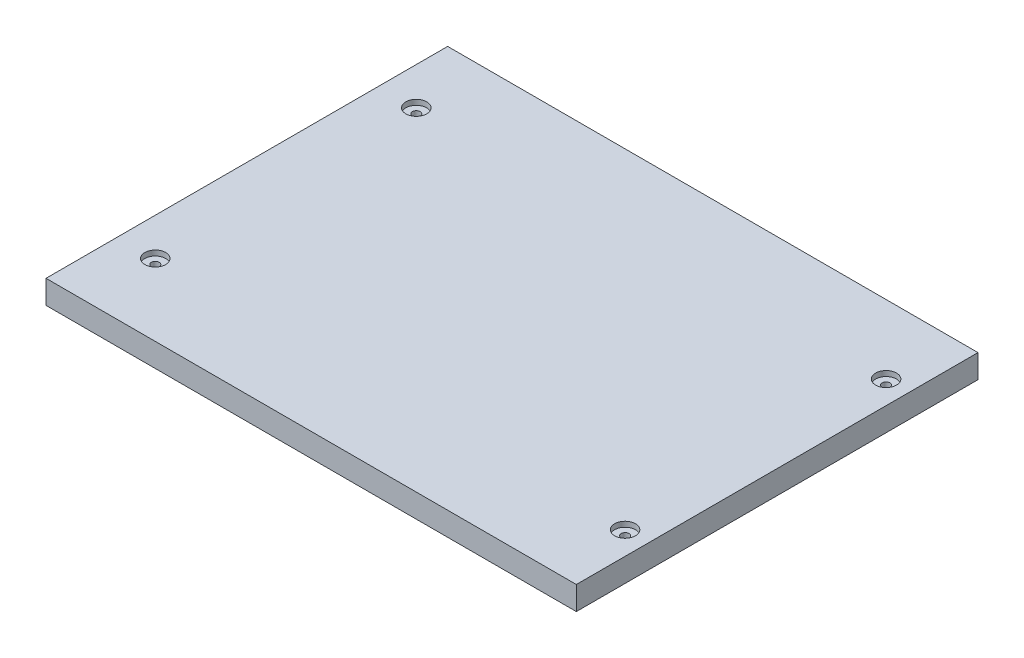
from build123d import *

# Parameters (mm, degrees)
SKETCH1_W               = 406.4
SKETCH1_H               = 307.8
BOSS_EXTRUDE1_DEPTH     = 18
SKETCH2_R               = 8
CUT_EXTRUDE1_DEPTH      = 4
SKETCH3_R               = 3
CUT_EXTRUDE2_DEPTH      = 5
CUT_EXTRUDE2_DEPTH_BACK = 15


with BuildPart() as part:
    # Sketch1 → Boss-Extrude1 (new body)
    with BuildSketch(Plane(origin=(0, 0, 0), x_dir=(1, 0, 0), z_dir=(0, 1, 0))):
        with Locations((203.2, 153.9)):
            Rectangle(SKETCH1_W, SKETCH1_H)
    extrude(amount=BOSS_EXTRUDE1_DEPTH)

    # Sketch2 → Cut-Extrude1 (cut)
    with BuildSketch(Plane(origin=(0, 18, 0), x_dir=(1, 0, 0), z_dir=(0, 1, 0))):
        with Locations((28.75, 55)):
            Circle(SKETCH2_R)
        with Locations((388.75, 255)):
            Circle(SKETCH2_R)
        with Locations((388.75, 55)):
            Circle(SKETCH2_R)
        with Locations((28.75, 255)):
            Circle(SKETCH2_R)
    extrude(amount=-CUT_EXTRUDE1_DEPTH, mode=Mode.SUBTRACT)

    # Sketch3 → Cut-Extrude2 (cut, two sides)
    with BuildSketch(Plane(origin=(0, 14, 0), x_dir=(1, 0, 0), z_dir=(0, 1, 0))) as cut_extrude2_sk:
        with Locations((28.75, 255)):
            Circle(SKETCH3_R)
        with Locations((28.75, 55)):
            Circle(SKETCH3_R)
        with Locations((388.75, 55)):
            Circle(SKETCH3_R)
        with Locations((388.75, 255)):
            Circle(SKETCH3_R)
    extrude(amount=CUT_EXTRUDE2_DEPTH, mode=Mode.SUBTRACT)
    extrude(cut_extrude2_sk.sketch, amount=-CUT_EXTRUDE2_DEPTH_BACK, mode=Mode.SUBTRACT)


solid = part.part
